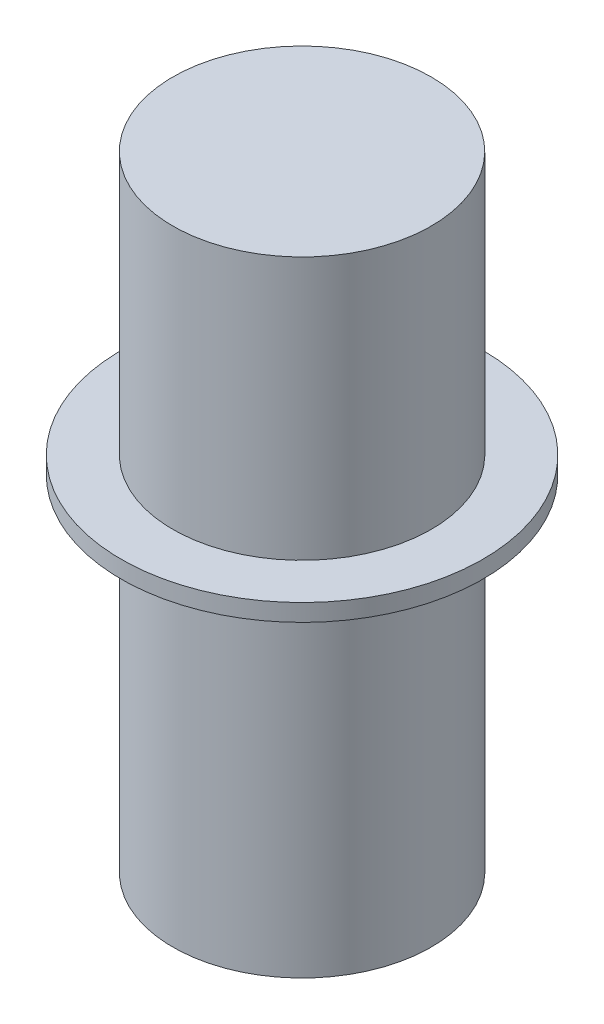
from build123d import *


with BuildPart() as part:
    # Esboço1 → Revolução1 (revolve)
    with BuildSketch(Plane.XY):
        Polygon((0, 0), (-15, 0), (-15, 40), (-21, 40), (-21, 42), (-15, 42), (-15, 72.5), (0, 72.5), align=None)
    revolve(axis=Axis((0, -22.49512947, 0), (0, 1, 0)))


solid = part.part
